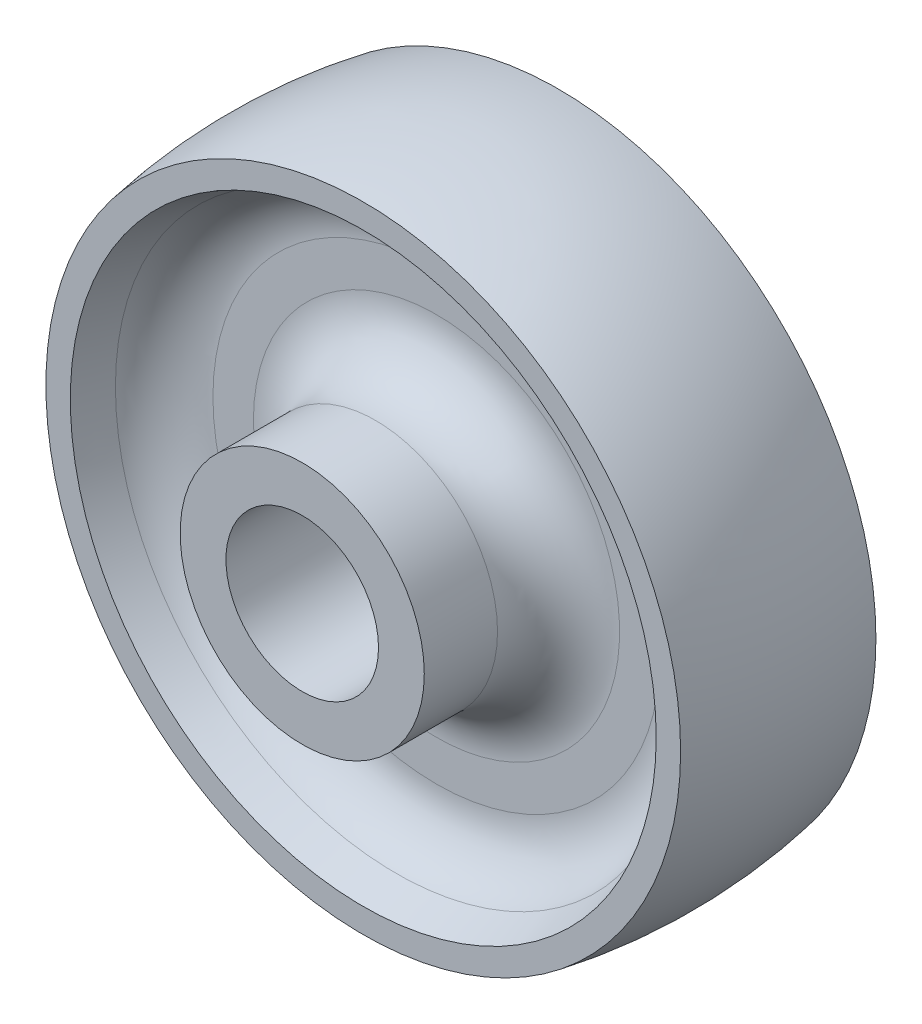
from build123d import *

# Parameters (mm, degrees)
RACCORDO1_R = 10
RACCORDO2_R = 10


with BuildPart() as part:
    # Schizzo1 → Rivoluzione1 (revolve)
    with BuildSketch(Plane(origin=(0, 0, 0), x_dir=(0, 0, -1), z_dir=(1, 0, 0))):
        with BuildLine():
            Line((26, 12.5), (-26, 12.5))
            Line((-26, 12.5), (-26, 20))
            Line((-26, 20), (-4, 20))
            Line((-4, 20), (-4, 43.632357189))
            Line((-4, 43.632357189), (-16, 48))
            Line((-16, 48), (-16, 52))
            ThreePointArc((-16, 52), (0, 53.433640698), (16, 52))
            Line((16, 52), (16, 48))
            Line((16, 48), (4, 43.632357189))
            Line((4, 43.632357189), (4, 20))
            Line((4, 20), (26, 20))
            Line((26, 20), (26, 12.5))
        make_face()
    revolve(axis=Axis((0, 0, 0), (0, 0, -1)))

    # Raccordo1
    raccordo1_edges = [part.edges().sort_by_distance(p)[0] for p in [
        (0, -43.632357189, -4),
        (0, -20, -4),
    ]]
    fillet(raccordo1_edges, radius=RACCORDO1_R)

    # Raccordo2
    raccordo2_edges = [part.edges().sort_by_distance(p)[0] for p in [
        (0, -43.632357189, 4),
        (0, -20, 4),
    ]]
    fillet(raccordo2_edges, radius=RACCORDO2_R)


solid = part.part
